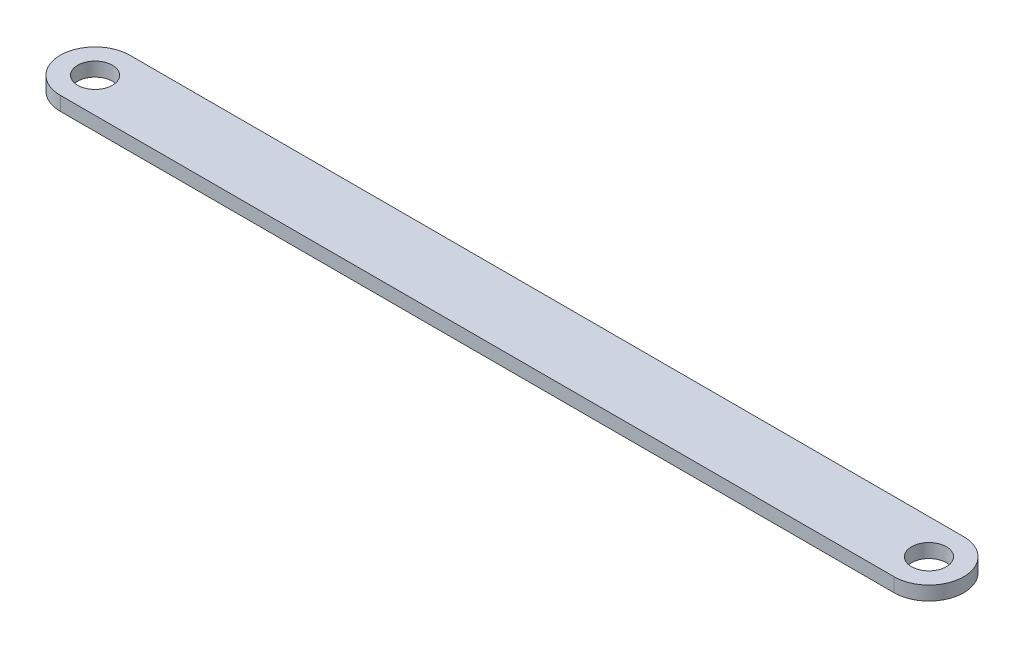
from build123d import *

# Parameters (mm, degrees)
SKETCH2_R           = 3.175
BOSS_EXTRUDE1_DEPTH = 1.27


with BuildPart() as part:
    # Sketch2 → Boss-Extrude1 (new body, symmetric)
    with BuildSketch(Plane(origin=(0, 0, 0), x_dir=(1, 0, 0), z_dir=(0, 1, 0))):
        with BuildLine():
            Line((-76.2, 6.35), (76.2, 6.35))
            ThreePointArc((76.2, 6.35), (82.55, 0), (76.2, -6.35))
            Line((76.2, -6.35), (-76.2, -6.35))
            ThreePointArc((-76.2, -6.35), (-82.55, 0), (-76.2, 6.35))
        make_face()
        with Locations((76.2, 0)):
            Circle(SKETCH2_R, mode=Mode.SUBTRACT)
        with Locations((-76.2, 0)):
            Circle(SKETCH2_R, mode=Mode.SUBTRACT)
    extrude(amount=BOSS_EXTRUDE1_DEPTH, both=True)


solid = part.part
